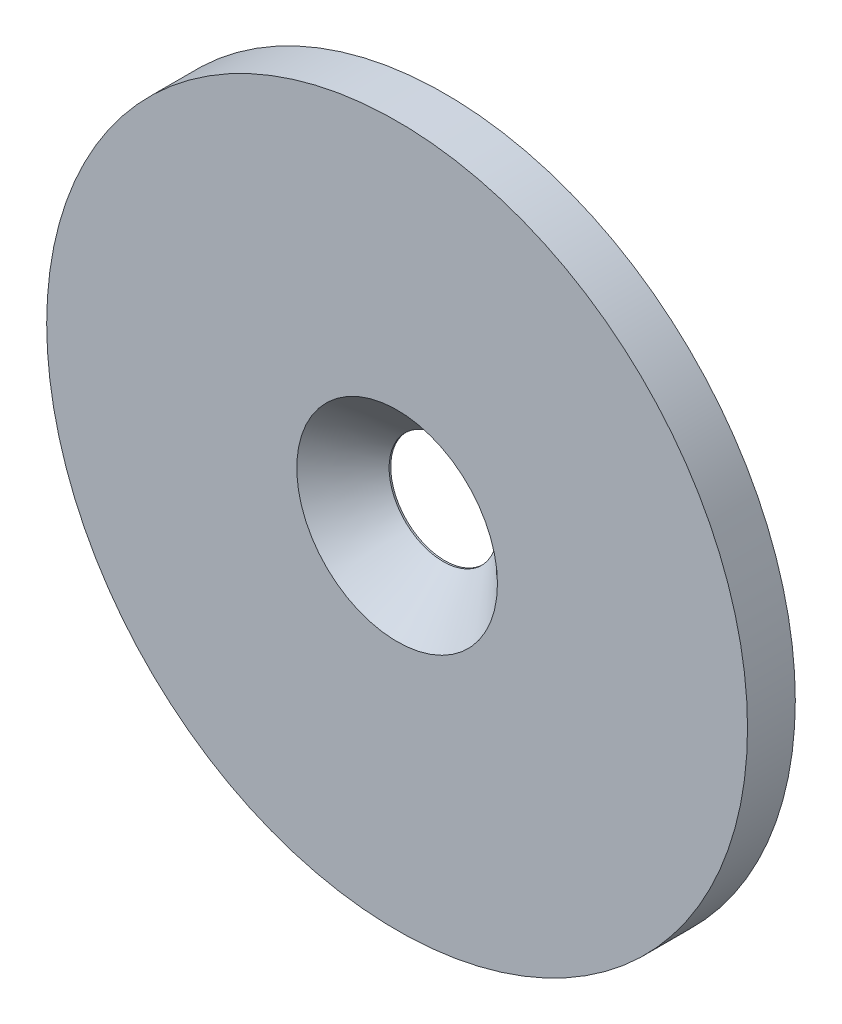
from build123d import *

# Parameters (mm, degrees)
SKETCH1_R           = 11
SKETCH1_R_2         = 1.5
BOSS_EXTRUDE1_DEPTH = 1.5


with BuildPart() as part:
    # Sketch1 → Boss-Extrude1 (new body)
    with BuildSketch(Plane.XY):
        Circle(SKETCH1_R)
        Circle(SKETCH1_R_2, mode=Mode.SUBTRACT)
    extrude(amount=BOSS_EXTRUDE1_DEPTH)

    # Sketch2 → CSK for M3 Flat Head Machine Screw1 (revolve, cut)
    with BuildSketch(Plane(origin=(0, 0, 1.5), x_dir=(0, -1, 0), z_dir=(1, 0, 0))):
        Polygon((0, 0), (0, 1.5), (1.7, 1.5), (1.7, 1.45), (3.15, 0), align=None)
    revolve(axis=Axis((0, 0, 7.85), (0, 0, -1)), mode=Mode.SUBTRACT)


solid = part.part
